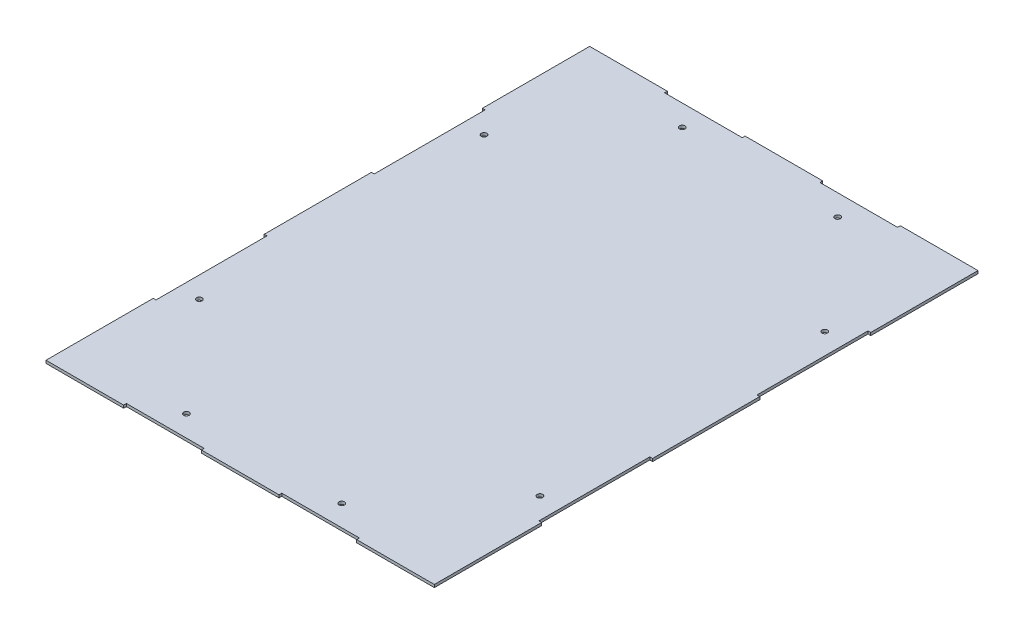
from build123d import *

# Parameters (mm, degrees)
SKETCH1_W           = 350
SKETCH1_H           = 490
BOSS_EXTRUDE1_DEPTH = 2.5
SKETCH2_R           = 2.5
SKETCH2_W           = 70
SKETCH2_H           = 2.5
SKETCH2_W_2         = 2.5
SKETCH2_H_2         = 100
CUT_EXTRUDE1_DEPTH  = 2.5


with BuildPart() as part:
    # Sketch1 → Boss-Extrude1 (new body)
    with BuildSketch(Plane(origin=(0, 0, 0), x_dir=(1, 0, 0), z_dir=(0, 1, 0))):
        Rectangle(SKETCH1_W, SKETCH1_H)
    extrude(amount=BOSS_EXTRUDE1_DEPTH)

    # Sketch2 → Cut-Extrude1 (cut)
    with BuildSketch(Plane(origin=(0, 2.5, 0), x_dir=(1, 0, 0), z_dir=(0, 1, 0))):
        with Locations((70, 223.5)):
            Circle(SKETCH2_R)
        with Locations((-70, 223.5)):
            Circle(SKETCH2_R)
        with Locations((70, -223.5)):
            Circle(SKETCH2_R)
        with Locations((-70, -223.5)):
            Circle(SKETCH2_R)
        with Locations((153.5, 128.333333333)):
            Circle(SKETCH2_R)
        with Locations((153.5, -128.333333333)):
            Circle(SKETCH2_R)
        with Locations((-153.5, -128.333333333)):
            Circle(SKETCH2_R)
        with Locations((-153.5, 128.333333333)):
            Circle(SKETCH2_R)
        with Locations((-70, 243.75)):
            Rectangle(SKETCH2_W, SKETCH2_H)
        with Locations((-173.75, 98.333333333)):
            Rectangle(SKETCH2_W_2, SKETCH2_H_2)
        with Locations((70, 243.75)):
            Rectangle(SKETCH2_W, SKETCH2_H)
        with Locations((-173.75, -98.333333333)):
            Rectangle(SKETCH2_W_2, SKETCH2_H_2)
        with Locations((173.75, -98.333333333)):
            Rectangle(SKETCH2_W_2, SKETCH2_H_2)
        with Locations((173.75, 98.333333333)):
            Rectangle(SKETCH2_W_2, SKETCH2_H_2)
        with Locations((70, -243.75)):
            Rectangle(SKETCH2_W, SKETCH2_H)
        with Locations((-70, -243.75)):
            Rectangle(SKETCH2_W, SKETCH2_H)
    extrude(amount=-CUT_EXTRUDE1_DEPTH, mode=Mode.SUBTRACT)


solid = part.part
